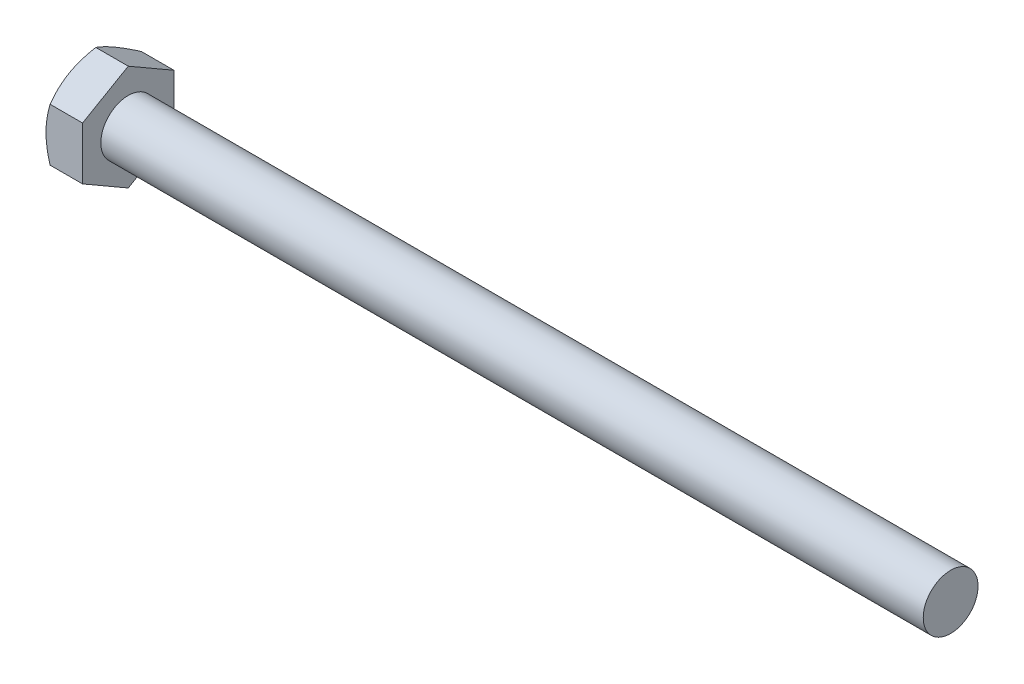
from build123d import *

# Parameters (mm, degrees)
BASEHEAD_DEPTH = 4
BODYSKE_W      = 94
BODYSKE_H      = 3


with BuildPart() as part:
    # Sketch1 → BaseHead (new body)
    with BuildSketch(Plane(origin=(0, 0, 0), x_dir=(0, 0, -1), z_dir=(1, 0, 0))):
        Polygon((5, 2.886751346), (5, -2.886751346), (0, -5.773502692), (-5, -2.886751346), (-5, 2.886751346), (0, 5.773502692), align=None)
    extrude(amount=BASEHEAD_DEPTH)

    # BodySke → BaseBody (revolve)
    with BuildSketch(Plane.XY):
        with Locations((47, 1.5)):
            Rectangle(BODYSKE_W, BODYSKE_H)
    revolve(axis=Axis((0, 0, 0), (1, 0, 0)))

    # Sketch3 → HeadChamfer (revolve, cut)
    with BuildSketch(Plane.XY):
        Polygon((0, 5), (3.333333333, 10.773502692), (3.333333333, 15.773502692), (-10, 15.773502692), (-10, 5), align=None)
    revolve(axis=Axis((0, 0, 0), (1, 0, 0)), mode=Mode.SUBTRACT)


solid = part.part
